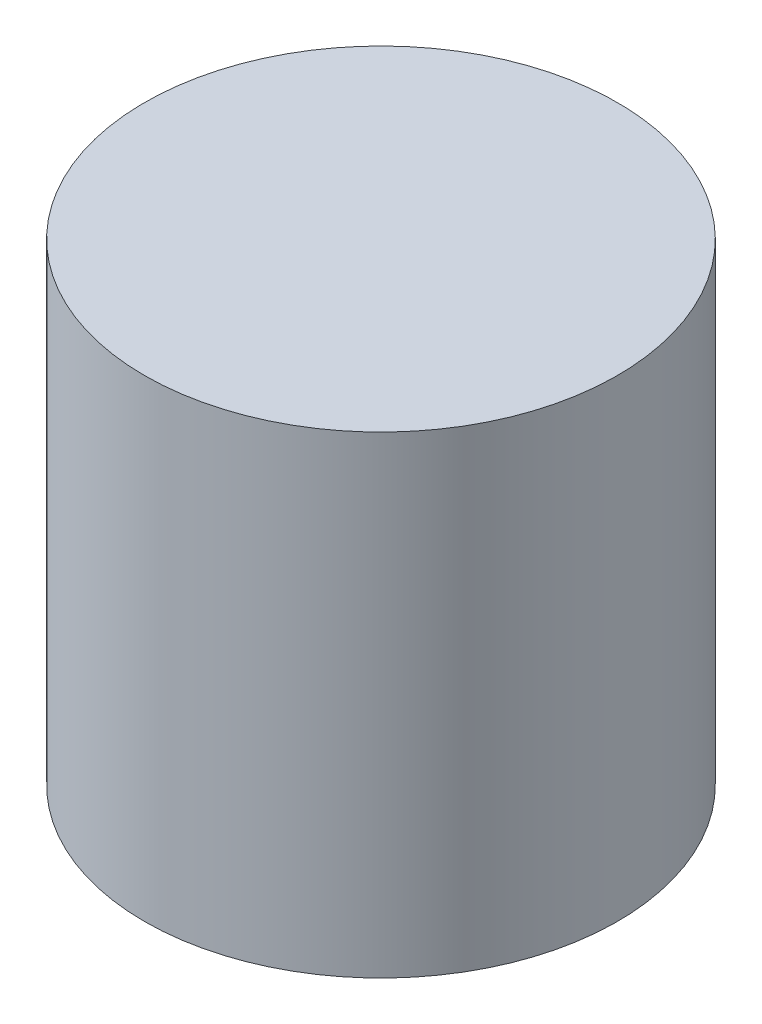
from build123d import *

# Parameters (mm, degrees)
SKETCH1_R           = 3
BOSS_EXTRUDE1_DEPTH = 6


with BuildPart() as part:
    # Sketch1 → Boss-Extrude1 (new body)
    with BuildSketch(Plane(origin=(0, 0, 0), x_dir=(1, 0, 0), z_dir=(0, 1, 0))):
        Circle(SKETCH1_R)
    extrude(amount=BOSS_EXTRUDE1_DEPTH)


solid = part.part
